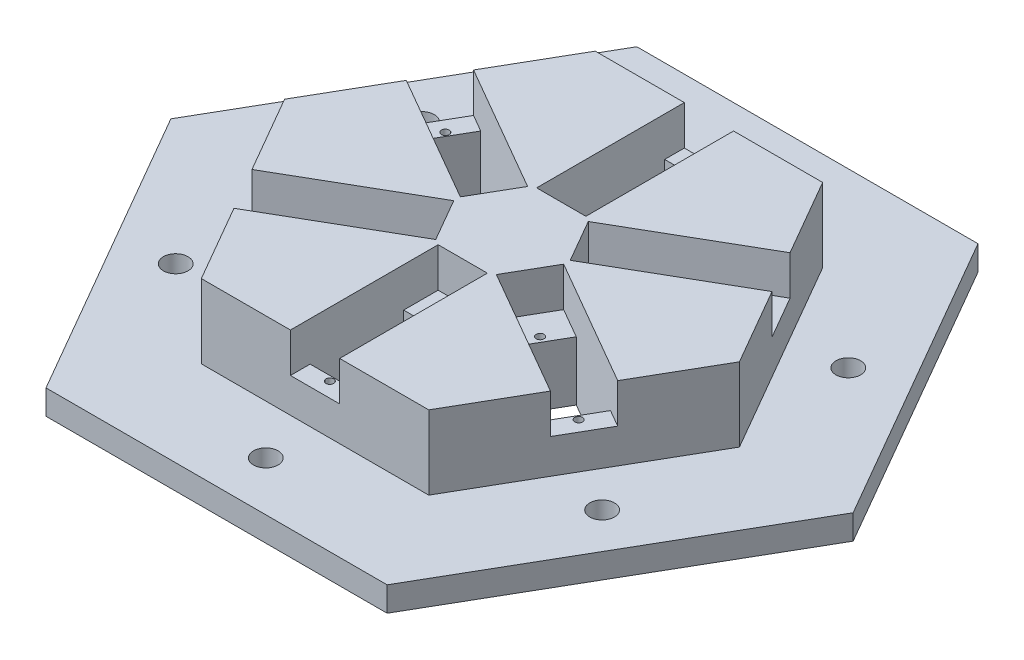
from build123d import *

# Parameters (mm, degrees)
BOSS_EXTRUDE1_DEPTH = 25.4
BOSS_EXTRUDE2_DEPTH = 6.35
SKETCH2_W           = 12.7
SKETCH2_H           = 38.1
CUT_EXTRUDE1_DEPTH  = 10.16
SKETCH3_W           = 12.7
SKETCH3_H           = 24.13
CUT_EXTRUDE2_DEPTH  = 118.390875284
SKETCH4_R           = 1.016
CUT_EXTRUDE3_DEPTH  = 12.7
SKETCH6_R           = 3.175
CUT_EXTRUDE4_DEPTH  = 118.946015193
CIRPATTERN1_COUNT   = 6


with BuildPart() as part:
    # Sketch1 → Boss-Extrude1 (new body)
    with BuildSketch(Plane(origin=(0, 0, 0), x_dir=(1, 0, 0), z_dir=(0, 1, 0))):
        Polygon((58.65878735, 0), (29.329393675, 50.8), (-29.329393675, 50.8), (-58.65878735, 0), (-29.329393675, -50.8), (29.329393675, -50.8), align=None)
    extrude(amount=BOSS_EXTRUDE1_DEPTH)

    # Sketch5 → Boss-Extrude2 (add)
    with BuildSketch(Plane.XZ):
        Polygon((87.988181024, 0), (43.994090512, 76.2), (-43.994090512, 76.2), (-87.988181024, 0), (-43.994090512, -76.2), (43.994090512, -76.2), align=None)
        Polygon((58.65878735, 0), (29.329393675, 50.8), (-29.329393675, 50.8), (-58.65878735, 0), (-29.329393675, -50.8), (29.329393675, -50.8), align=None, mode=Mode.SUBTRACT)
    extrude(amount=-BOSS_EXTRUDE2_DEPTH)

    # Sketch2 → Cut-Extrude1 (cut)
    with BuildSketch(Plane(origin=(0, 25.4, 0), x_dir=(1, 0, 0), z_dir=(0, 1, 0))):
        with Locations((0, -31.75)):
            Rectangle(SKETCH2_W, SKETCH2_H)
    cut_extrude1 = extrude(amount=-CUT_EXTRUDE1_DEPTH, mode=Mode.SUBTRACT)

    # Sketch3 → Cut-Extrude2 (cut, through all)
    with BuildSketch(Plane(origin=(0, 15.24, 0), x_dir=(1, 0, 0), z_dir=(0, 1, 0))):
        with Locations((0, -33.655)):
            Rectangle(SKETCH3_W, SKETCH3_H)
    cut_extrude2 = extrude(amount=-CUT_EXTRUDE2_DEPTH, mode=Mode.SUBTRACT)

    # Sketch4 → Cut-Extrude3 (cut)
    with BuildSketch(Plane(origin=(0, 15.24, 0), x_dir=(1, 0, 0), z_dir=(0, 1, 0))):
        with Locations((0, -19.812)):
            Circle(SKETCH4_R)
        with Locations((0, -46.99)):
            Circle(SKETCH4_R)
    cut_extrude3 = extrude(amount=-CUT_EXTRUDE3_DEPTH, mode=Mode.SUBTRACT)

    # Sketch6 → Cut-Extrude4 (cut, through all)
    with BuildSketch(Plane(origin=(0, 6.35, 0), x_dir=(1, 0, 0), z_dir=(0, 1, 0))):
        with Locations((0, -63.5)):
            Circle(SKETCH6_R)
    cut_extrude4 = extrude(amount=-CUT_EXTRUDE4_DEPTH, mode=Mode.SUBTRACT)

    # CirPattern1: Cut-Extrude1, Cut-Extrude2, Cut-Extrude3, Cut-Extrude4 ×6 about axis
    cirpattern1_axis = Axis((0, 26.67, 0), (0, -1, 0))
    add([cut_extrude1.rotate(cirpattern1_axis, i * 360 / CIRPATTERN1_COUNT) for i in range(1, CIRPATTERN1_COUNT)], mode=Mode.SUBTRACT)
    add([cut_extrude2.rotate(cirpattern1_axis, i * 360 / CIRPATTERN1_COUNT) for i in range(1, CIRPATTERN1_COUNT)], mode=Mode.SUBTRACT)
    add([cut_extrude3.rotate(cirpattern1_axis, i * 360 / CIRPATTERN1_COUNT) for i in range(1, CIRPATTERN1_COUNT)], mode=Mode.SUBTRACT)
    add([cut_extrude4.rotate(cirpattern1_axis, i * 360 / CIRPATTERN1_COUNT) for i in range(1, CIRPATTERN1_COUNT)], mode=Mode.SUBTRACT)


solid = part.part
